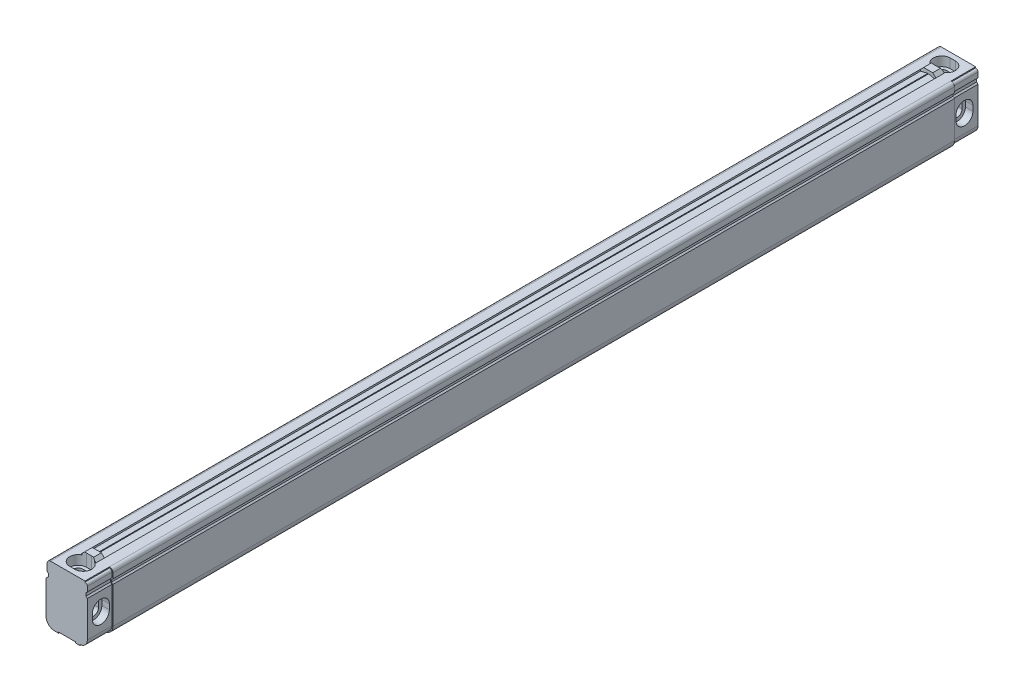
from build123d import *

# Parameters (mm, degrees)
EXTRUDE_1_DEPTH          = 526
SKETCH_2_W               = 10
SKETCH_2_H               = 0.6
CUT_EXTRUDE_1_DEPTH      = 14.5
EXTRUDE_START            = -12.5
EXTRUDE_2_DEPTH          = 5
CUT_EXTRUDE_2_DEPTH      = 4.4
CUT_EXTRUDE_3_DEPTH      = 26
CUT_EXTRUDE_4_DEPTH      = 5.5
CUT_EXTRUDE_4_DEPTH_BACK = 5.5
CUT_EXTRUDE_5_DEPTH      = 35.5
SKETCH_8_W               = 0.5
SKETCH_8_H               = 1
CUT_EXTRUDE_8_DEPTH      = 491


with BuildPart() as part:
    # Эскиз1 → Бобышка-Вытянуть1 (new body)
    with BuildSketch(Plane.XY):
        with BuildLine():
            Line((-11.8, 32.5), (-11.8, 28.3))
            Line((-11.8, 28.3), (-11, 27.5))
            Line((-11, 27.5), (-11, 26))
            Line((-11, 26), (-12.5, 24.5))
            Line((-12.5, 24.5), (-12.5, 5))
            ThreePointArc((-12.5, 5), (-11.035533906, 1.464466094), (-7.5, 0))
            Line((-7.5, 0), (7.5, 0))
            ThreePointArc((7.5, 0), (11.035533906, 1.464466094), (12.5, 5))
            Line((12.5, 5), (12.5, 26.5))
            Line((12.5, 26.5), (11.7, 27.3))
            Line((11.7, 27.3), (11.7, 28.5))
            Line((11.7, 28.5), (12.5, 29.3))
            Line((12.5, 29.3), (12.5, 32.5))
            ThreePointArc((12.5, 32.5), (11.914213562, 33.914213562), (10.5, 34.5))
            Line((10.5, 34.5), (-9.8, 34.5))
            ThreePointArc((-9.8, 34.5), (-11.214213562, 33.914213562), (-11.8, 32.5))
        make_face()
    extrude(amount=EXTRUDE_1_DEPTH)

    # Эскиз2 → Вырез-Вытянуть1 (cut)
    with BuildSketch(Plane(origin=(0, 0, 0), x_dir=(-1, 0, 0), z_dir=(0, 0, -1))):
        with BuildLine():
            ThreePointArc((-10.5, 33.9), (-11.489949494, 33.489949494), (-11.9, 32.5))
            Line((-11.9, 32.5), (-11.9, 29.548528137))
            Line((-11.9, 29.548528137), (-11.1, 28.748528137))
            Line((-11.1, 28.748528137), (-11.1, 27.051471863))
            Line((-11.1, 27.051471863), (-11.9, 26.251471863))
            Line((-11.9, 26.251471863), (-11.9, 5))
            ThreePointArc((-11.9, 5), (-10.611269837, 1.888730163), (-7.5, 0.6))
            Line((-7.5, 0.6), (-7.5, 0))
            ThreePointArc((-7.5, 0), (-11.035533906, 1.464466094), (-12.5, 5))
            Line((-12.5, 5), (-12.5, 26.5))
            Line((-12.5, 26.5), (-11.7, 27.3))
            Line((-11.7, 27.3), (-11.7, 28.5))
            Line((-11.7, 28.5), (-12.5, 29.3))
            Line((-12.5, 29.3), (-12.5, 32.5))
            ThreePointArc((-12.5, 32.5), (-11.914213562, 33.914213562), (-10.5, 34.5))
            Line((-10.5, 34.5), (-10.5, 33.9))
        make_face()
        with Locations((0, 0.3)):
            Rectangle(SKETCH_2_W, SKETCH_2_H)
    cut_extrude_1 = extrude(amount=-CUT_EXTRUDE_1_DEPTH, mode=Mode.SUBTRACT)

    # Эскиз5 → Бобышка-Вытянуть2 (add)
    with BuildSketch(Plane.XY.offset(526).offset(EXTRUDE_START)):
        Polygon((-4.5, 34.5), (-2.7, 36.3), (2.7, 36.3), (4.5, 34.5), align=None)
    extrude_2 = extrude(amount=-EXTRUDE_2_DEPTH)

    # Зеркальное отражение1: Вырез-Вытянуть1, Бобышка-Вытянуть2 across plane
    add(cut_extrude_1.mirror(Plane.XY.offset(263)), mode=Mode.SUBTRACT)
    add(extrude_2.mirror(Plane.XY.offset(263)))

    # Эскиз3 → Вырез-Вытянуть2 (cut)
    with BuildSketch(Plane(origin=(11.9, 0, 0), x_dir=(0, 0, -1), z_dir=(1, 0, 0))):
        with BuildLine():
            Line((-523, 14), (-523, 17))
            ThreePointArc((-523, 17), (-518, 22), (-513, 17))
            Line((-513, 17), (-513, 14))
            ThreePointArc((-513, 14), (-518, 9), (-523, 14))
        make_face()
        with BuildLine():
            Line((-3, 14), (-3, 17))
            ThreePointArc((-3, 17), (-8, 22), (-13, 17))
            Line((-13, 17), (-13, 14))
            ThreePointArc((-13, 14), (-8, 9), (-3, 14))
        make_face()
    extrude(amount=-CUT_EXTRUDE_2_DEPTH, mode=Mode.SUBTRACT)

    # Эскиз4 → Вырез-Вытянуть3 (cut, through all)
    with BuildSketch(Plane(origin=(12.5, 0, 0), x_dir=(0, 0, -1), z_dir=(1, 0, 0))):
        with BuildLine():
            Line((-521, 14), (-521, 17))
            ThreePointArc((-521, 17), (-518, 20), (-515, 17))
            Line((-515, 17), (-515, 14))
            ThreePointArc((-515, 14), (-518, 11), (-521, 14))
        make_face()
        with BuildLine():
            Line((-5, 14), (-5, 17))
            ThreePointArc((-5, 17), (-8, 20), (-11, 17))
            Line((-11, 17), (-11, 14))
            ThreePointArc((-11, 14), (-8, 11), (-5, 14))
        make_face()
    extrude(amount=-CUT_EXTRUDE_3_DEPTH, mode=Mode.SUBTRACT)

    # Эскиз6 → Вырез-Вытянуть4 (cut, two sides)
    with BuildSketch(Plane(origin=(0, 34.5, 0), x_dir=(1, 0, 0), z_dir=(0, 1, 0))) as cut_extrude_4_sk:
        with BuildLine():
            Line((-1.5, -3), (1.5, -3))
            ThreePointArc((1.5, -3), (6.5, -8), (1.5, -13))
            Line((1.5, -13), (-1.5, -13))
            ThreePointArc((-1.5, -13), (-6.5, -8), (-1.5, -3))
        make_face()
        with BuildLine():
            Line((-1.5, -513), (1.5, -513))
            ThreePointArc((1.5, -513), (6.5, -518), (1.5, -523))
            Line((1.5, -523), (-1.5, -523))
            ThreePointArc((-1.5, -523), (-6.5, -518), (-1.5, -513))
        make_face()
    extrude(amount=CUT_EXTRUDE_4_DEPTH, mode=Mode.SUBTRACT)
    extrude(cut_extrude_4_sk.sketch, amount=-CUT_EXTRUDE_4_DEPTH_BACK, mode=Mode.SUBTRACT)

    # Эскиз7 → Вырез-Вытянуть5 (cut, through all)
    with BuildSketch(Plane(origin=(0, 34.5, 0), x_dir=(1, 0, 0), z_dir=(0, 1, 0))):
        with BuildLine():
            Line((-1.5, -515), (1.5, -515))
            ThreePointArc((1.5, -515), (4.5, -518), (1.5, -521))
            Line((1.5, -521), (-1.5, -521))
            ThreePointArc((-1.5, -521), (-4.5, -518), (-1.5, -515))
        make_face()
        with BuildLine():
            Line((-1.5, -5), (1.5, -5))
            ThreePointArc((1.5, -5), (4.5, -8), (1.5, -11))
            Line((1.5, -11), (-1.5, -11))
            ThreePointArc((-1.5, -11), (-4.5, -8), (-1.5, -5))
        make_face()
    extrude(amount=-CUT_EXTRUDE_5_DEPTH, mode=Mode.SUBTRACT)

    # Эскиз8 → Вырез-Вытянуть8 (cut)
    with BuildSketch(Plane.XY.offset(17.5)):
        Polygon((-0.25, 34.5), (-4.5, 34.5), (-4.5, 33.5), align=None)
        with Locations((0, 34)):
            Rectangle(SKETCH_8_W, SKETCH_8_H)
        Polygon((4.5, 34.5), (0.25, 34.5), (4.5, 33.5), align=None)
    extrude(amount=CUT_EXTRUDE_8_DEPTH, mode=Mode.SUBTRACT)


solid = part.part
